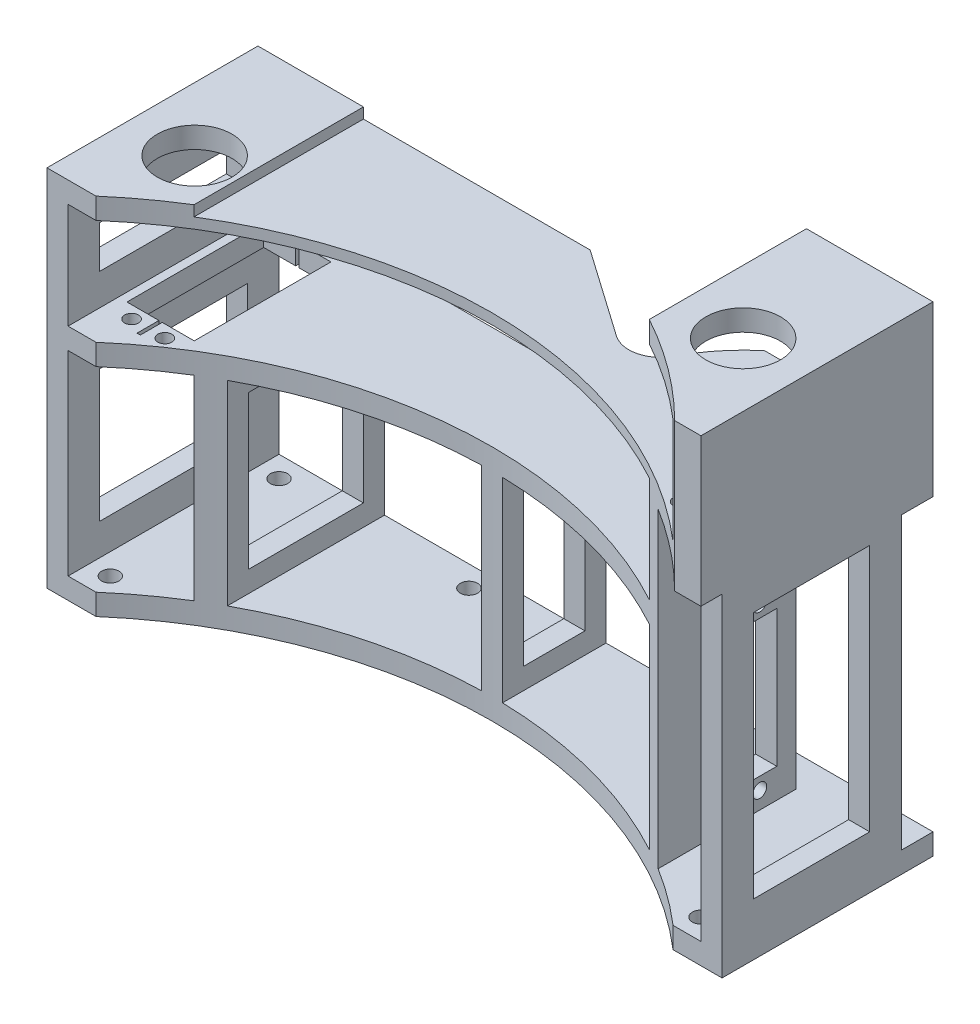
from build123d import *

# Parameters (mm, degrees)
SKETCH1_W               = 203.2
SKETCH1_H               = 106.425000002
BOSS_EXTRUDE1_DEPTH     = 31.75
SKETCH4_W               = 190.5
SKETCH4_H               = 31.75
SKETCH4_H_2             = 58.800000002
CUT_EXTRUDE2_DEPTH      = 64.5
BOSS_EXTRUDE2_START     = -31.75
SKETCH8_W               = 6.35
SKETCH8_H               = 58.800000002
SKETCH8_H_2             = 96.900000002
BOSS_EXTRUDE2_DEPTH     = 63.5
SKETCH15_W              = 25.4
SKETCH15_H              = 63.5
BOSS_EXTRUDE4_DEPTH     = 3.175
CUT_EXTRUDE3_REACH      = 73.5
SKETCH2_R               = 2.099999991
SKETCH2_W               = 25.4
SKETCH2_H               = 63.5
CUT_EXTRUDE4_REACH      = 108.425
SKETCH9_R               = 2.099999991
CUT_EXTRUDE7_START      = -1
SKETCH12_R              = 2.600000007
CUT_EXTRUDE7_DEPTH      = 7.35
SKETCH16_W              = 31.75
SKETCH16_H              = 63.5
BOSS_EXTRUDE5_DEPTH     = 3.175
CUT_EXTRUDE8_REACH      = 111.6
SKETCH17_R              = 11.2395
BOSS_EXTRUDE6_START     = -6.35
BOSS_EXTRUDE6_DEPTH     = 38.1
SKETCH20_W              = 38.1
SKETCH20_H              = 69.85
SKETCH20_R              = 11.2395
BOSS_EXTRUDE7_DEPTH     = 6.35
SKETCH10_R              = 132.699248966
CUT_EXTRUDE5_DEPTH      = 39.1
CUT_EXTRUDE5_DEPTH_BACK = 107.425000002
CUT_EXTRUDE10_DEPTH     = 3.175
SKETCH23_W              = 44.45
SKETCH23_H              = 87.375000002
CUT_EXTRUDE11_DEPTH     = 9.525
CUT_EXTRUDE12_REACH     = 40.1
SKETCH24_R              = 2.099999991
CUT_EXTRUDE13_REACH     = 8.35
SKETCH26_W              = 34.925
SKETCH26_H              = 74.675000002
CUT_EXTRUDE14_REACH     = 40.1
SKETCH27_W              = 25.085299193
SKETCH27_H              = 19.05
CUT_EXTRUDE15_REACH     = 106.775
SKETCH28_W              = 18.468739448
SKETCH28_H              = 46.100000002
CUT_EXTRUDE16_REACH     = 40.1
SKETCH29_W              = 34.610299193
SKETCH29_H              = 46.100000002
CUT_EXTRUDE17_REACH     = 8.35
SKETCH30_W              = 44.45
SKETCH30_H              = 39.750000002
CUT_EXTRUDE18_REACH     = 8.35
SKETCH31_W              = 44.45
SKETCH31_H              = 12.7
FILLET1_R               = 9.525


with BuildPart() as part:
    # Sketch1 → Boss-Extrude1 (new body, symmetric)
    with BuildSketch(Plane.XY):
        with Locations((0, 53.212500001)):
            Rectangle(SKETCH1_W, SKETCH1_H)
    extrude(amount=BOSS_EXTRUDE1_DEPTH, both=True)

    # Sketch4 → Cut-Extrude2 (cut, through all)
    with BuildSketch(Plane(origin=(0, 0, -31.75), x_dir=(-1, 0, 0), z_dir=(0, 0, -1))):
        with Locations((0, 87.375000002)):
            Rectangle(SKETCH4_W, SKETCH4_H)
        with Locations((0, 35.750000001)):
            Rectangle(SKETCH4_W, SKETCH4_H_2)
    extrude(amount=-CUT_EXTRUDE2_DEPTH, mode=Mode.SUBTRACT)

    # Sketch8 → Boss-Extrude2 (add)
    with BuildSketch(Plane.XY.offset(BOSS_EXTRUDE2_START)):
        with Locations((-66.675, 35.750000001)):
            Rectangle(SKETCH8_W, SKETCH8_H)
        with Locations((66.675, 54.800000001)):
            Rectangle(SKETCH8_W, SKETCH8_H_2)
        with Locations((0, 35.750000001)):
            Rectangle(SKETCH8_W, SKETCH8_H)
    extrude(amount=BOSS_EXTRUDE2_DEPTH)

    # Sketch15 → Boss-Extrude4 (add)
    with BuildSketch(Plane.XZ.offset(-103.250000002)):
        with Locations((82.55, 0)):
            Rectangle(SKETCH15_W, SKETCH15_H)
    extrude(amount=BOSS_EXTRUDE4_DEPTH)

    # Sketch2 → Cut-Extrude3 (cut, up to next)
    with BuildSketch(Plane(origin=(0, 71.500000002, 0), x_dir=(1, 0, 0), z_dir=(0, 1, 0)), mode=Mode.PRIVATE) as cut_extrude3_sk1:
        with Locations((-87.550000033, -20.327000113)):
            Circle(SKETCH2_R)
    cut_extrude3_tool1 = extrude(cut_extrude3_sk1.sketch, amount=-CUT_EXTRUDE3_REACH, mode=Mode.PRIVATE) & part.part
    add(cut_extrude3_tool1.solids().sort_by_distance((-87.55, 71.5, 20.327))[0], mode=Mode.SUBTRACT)
    # Sketch2 → Cut-Extrude3 (cut, up to next)
    with BuildSketch(Plane(origin=(0, 71.500000002, 0), x_dir=(1, 0, 0), z_dir=(0, 1, 0)), mode=Mode.PRIVATE) as cut_extrude3_sk2:
        with Locations((-77.549999967, -20.327000113)):
            Circle(SKETCH2_R)
    cut_extrude3_tool2 = extrude(cut_extrude3_sk2.sketch, amount=-CUT_EXTRUDE3_REACH, mode=Mode.PRIVATE) & part.part
    add(cut_extrude3_tool2.solids().sort_by_distance((-77.55, 71.5, 20.327))[0], mode=Mode.SUBTRACT)
    # Sketch2 → Cut-Extrude3 (cut, up to next)
    with BuildSketch(Plane(origin=(0, 71.500000002, 0), x_dir=(1, 0, 0), z_dir=(0, 1, 0)), mode=Mode.PRIVATE) as cut_extrude3_sk3:
        with Locations((-87.550000033, 28.272999969)):
            Circle(SKETCH2_R)
    cut_extrude3_tool3 = extrude(cut_extrude3_sk3.sketch, amount=-CUT_EXTRUDE3_REACH, mode=Mode.PRIVATE) & part.part
    add(cut_extrude3_tool3.solids().sort_by_distance((-87.55, 71.5, -28.273))[0], mode=Mode.SUBTRACT)
    # Sketch2 → Cut-Extrude3 (cut, up to next)
    with BuildSketch(Plane(origin=(0, 71.500000002, 0), x_dir=(1, 0, 0), z_dir=(0, 1, 0)), mode=Mode.PRIVATE) as cut_extrude3_sk4:
        with Locations((-77.549999967, 28.272999969)):
            Circle(SKETCH2_R)
    cut_extrude3_tool4 = extrude(cut_extrude3_sk4.sketch, amount=-CUT_EXTRUDE3_REACH, mode=Mode.PRIVATE) & part.part
    add(cut_extrude3_tool4.solids().sort_by_distance((-77.55, 71.5, -28.273))[0], mode=Mode.SUBTRACT)
    # Sketch2 → Cut-Extrude3 (cut, up to next)
    with BuildSketch(Plane(origin=(0, 71.500000002, 0), x_dir=(1, 0, 0), z_dir=(0, 1, 0)), mode=Mode.PRIVATE) as cut_extrude3_sk5:
        Polygon((-92.676999939, 24.549999922), (-83.05, 24.549999922), (-83.05, 31.153999922), (-82.05, 31.153999922), (-82.05, 24.549999922), (-72.423000061, 24.549999922), (-72.423000061, -16.604000066), (-82.05, -16.604000066), (-82.05, -23.208000066), (-83.05, -23.208000066), (-83.05, -16.604000066), (-92.676999939, -16.604000066), align=None)
    cut_extrude3_tool5 = extrude(cut_extrude3_sk5.sketch, amount=-CUT_EXTRUDE3_REACH, mode=Mode.PRIVATE) & part.part
    add(cut_extrude3_tool5.solids().sort_by_distance((-82.55, 71.5, -3.973))[0], mode=Mode.SUBTRACT)
    # Sketch2 → Cut-Extrude3 (cut, up to next)
    with BuildSketch(Plane(origin=(0, 71.500000002, 0), x_dir=(1, 0, 0), z_dir=(0, 1, 0)), mode=Mode.PRIVATE) as cut_extrude3_sk6:
        with Locations((82.55, 0)):
            Rectangle(SKETCH2_W, SKETCH2_H)
    cut_extrude3_tool6 = extrude(cut_extrude3_sk6.sketch, amount=-CUT_EXTRUDE3_REACH, mode=Mode.PRIVATE) & part.part
    add(cut_extrude3_tool6.solids().sort_by_distance((82.55, 71.5, 0))[0], mode=Mode.SUBTRACT)

    # Sketch9 → Cut-Extrude4 (cut, up to next)
    with BuildSketch(Plane(origin=(0, 106.425000002, 0), x_dir=(1, 0, 0), z_dir=(0, 1, 0)), mode=Mode.PRIVATE) as cut_extrude4_sk1:
        with Locations((77.549999967, -20.327000113)):
            Circle(SKETCH9_R)
    cut_extrude4_tool1 = extrude(cut_extrude4_sk1.sketch, amount=-CUT_EXTRUDE4_REACH, mode=Mode.PRIVATE) & part.part
    add(cut_extrude4_tool1.solids().sort_by_distance((77.55, 106.425, 20.327))[0], mode=Mode.SUBTRACT)
    # Sketch9 → Cut-Extrude4 (cut, up to next)
    with BuildSketch(Plane(origin=(0, 106.425000002, 0), x_dir=(1, 0, 0), z_dir=(0, 1, 0)), mode=Mode.PRIVATE) as cut_extrude4_sk2:
        with Locations((87.550000033, -20.327000113)):
            Circle(SKETCH9_R)
    cut_extrude4_tool2 = extrude(cut_extrude4_sk2.sketch, amount=-CUT_EXTRUDE4_REACH, mode=Mode.PRIVATE) & part.part
    add(cut_extrude4_tool2.solids().sort_by_distance((87.55, 106.425, 20.327))[0], mode=Mode.SUBTRACT)
    # Sketch9 → Cut-Extrude4 (cut, up to next)
    with BuildSketch(Plane(origin=(0, 106.425000002, 0), x_dir=(1, 0, 0), z_dir=(0, 1, 0)), mode=Mode.PRIVATE) as cut_extrude4_sk3:
        with Locations((77.549999967, 28.272999969)):
            Circle(SKETCH9_R)
    cut_extrude4_tool3 = extrude(cut_extrude4_sk3.sketch, amount=-CUT_EXTRUDE4_REACH, mode=Mode.PRIVATE) & part.part
    add(cut_extrude4_tool3.solids().sort_by_distance((77.55, 106.425, -28.273))[0], mode=Mode.SUBTRACT)
    # Sketch9 → Cut-Extrude4 (cut, up to next)
    with BuildSketch(Plane(origin=(0, 106.425000002, 0), x_dir=(1, 0, 0), z_dir=(0, 1, 0)), mode=Mode.PRIVATE) as cut_extrude4_sk4:
        with Locations((87.550000033, 28.272999969)):
            Circle(SKETCH9_R)
    cut_extrude4_tool4 = extrude(cut_extrude4_sk4.sketch, amount=-CUT_EXTRUDE4_REACH, mode=Mode.PRIVATE) & part.part
    add(cut_extrude4_tool4.solids().sort_by_distance((87.55, 106.425, -28.273))[0], mode=Mode.SUBTRACT)
    # Sketch9 → Cut-Extrude4 (cut, up to next)
    with BuildSketch(Plane(origin=(0, 106.425000002, 0), x_dir=(1, 0, 0), z_dir=(0, 1, 0)), mode=Mode.PRIVATE) as cut_extrude4_sk5:
        Polygon((72.423000061, 24.549999922), (82.05, 24.549999922), (82.05, 31.153999922), (83.05, 31.153999922), (83.05, 24.549999922), (92.676999939, 24.549999922), (92.676999939, -16.604000066), (83.05, -16.604000066), (83.05, -23.208000066), (82.05, -23.208000066), (82.05, -16.604000066), (72.423000061, -16.604000066), align=None)
    cut_extrude4_tool5 = extrude(cut_extrude4_sk5.sketch, amount=-CUT_EXTRUDE4_REACH, mode=Mode.PRIVATE) & part.part
    add(cut_extrude4_tool5.solids().sort_by_distance((82.55, 106.425, -3.973))[0], mode=Mode.SUBTRACT)

    # Sketch12 → Cut-Extrude7 (cut)
    with BuildSketch(Plane(origin=(0, 0, 0), x_dir=(1, 0, 0), z_dir=(0, 1, 0)).offset(CUT_EXTRUDE7_START)):
        with Locations((-88.9, 25.4)):
            Circle(SKETCH12_R)
        with Locations((-88.9, -25.4)):
            Circle(SKETCH12_R)
        with Locations((-31.75, 25.4)):
            Circle(SKETCH12_R)
    cut_extrude7 = extrude(amount=CUT_EXTRUDE7_DEPTH, mode=Mode.SUBTRACT)

    # Mirror1: Cut-Extrude7 across plane
    add(cut_extrude7.mirror(Plane(origin=(0, 0, 0), x_dir=(0, 0, 1), z_dir=(1, 0, 0))), mode=Mode.SUBTRACT)

    # Sketch16 → Boss-Extrude5 (add)
    with BuildSketch(Plane(origin=(0, 106.425000002, 0), x_dir=(1, 0, 0), z_dir=(0, 1, 0))):
        with Locations((-85.725, 0)):
            Rectangle(SKETCH16_W, SKETCH16_H)
    extrude(amount=BOSS_EXTRUDE5_DEPTH)

    # Sketch17 → Cut-Extrude8 (cut, up to next)
    with BuildSketch(Plane(origin=(0, 109.600000002, 0), x_dir=(1, 0, 0), z_dir=(0, 1, 0)), mode=Mode.PRIVATE) as cut_extrude8_sk1:
        with Locations((-82.55, -6.35)):
            Circle(SKETCH17_R)
    cut_extrude8_tool1 = extrude(cut_extrude8_sk1.sketch, amount=-CUT_EXTRUDE8_REACH, mode=Mode.PRIVATE) & part.part
    add(cut_extrude8_tool1.solids().sort_by_distance((-82.55, 109.6, 6.35))[0], mode=Mode.SUBTRACT)

    # Sketch18 → Boss-Extrude6 (add)
    with BuildSketch(Plane(origin=(0, 106.425000002, 0), x_dir=(1, 0, 0), z_dir=(0, 1, 0)).offset(BOSS_EXTRUDE6_START)):
        Polygon((101.6, -31.75), (101.6, 31.75), (95.25, 31.75), (95.25, -31.75), (82.55, -31.75), (82.55, -38.1), (101.6, -38.1), align=None)
    extrude(amount=BOSS_EXTRUDE6_DEPTH)

    # Sketch20 → Boss-Extrude7 (add)
    with BuildSketch(Plane(origin=(0, 138.175000002, 0), x_dir=(1, 0, 0), z_dir=(0, 1, 0))):
        with Locations((82.55, -3.175)):
            Rectangle(SKETCH20_W, SKETCH20_H)
        with Locations((82.55, -6.35)):
            Circle(SKETCH20_R, mode=Mode.SUBTRACT)
    extrude(amount=BOSS_EXTRUDE7_DEPTH)

    # Sketch10 → Cut-Extrude5 (cut, two sides)
    with BuildSketch(Plane(origin=(0, 106.425000002, 0), x_dir=(1, 0, 0), z_dir=(0, 1, 0))) as cut_extrude5_sk:
        with Locations((0, -132.08)):
            Circle(SKETCH10_R)
    extrude(amount=CUT_EXTRUDE5_DEPTH, mode=Mode.SUBTRACT)
    extrude(cut_extrude5_sk.sketch, amount=-CUT_EXTRUDE5_DEPTH_BACK, mode=Mode.SUBTRACT)

    # Sketch21 → Cut-Extrude10 (cut)
    with BuildSketch(Plane(origin=(0, 106.425000002, 0), x_dir=(1, 0, 0), z_dir=(0, 1, 0))):
        with BuildLine():
            Line((34.675884865, 6.35), (-1.599074507, 31.75))
            Line((-1.599074507, 31.75), (50.901763082, 31.75))
            ThreePointArc((50.901763082, 31.75), (40.809838057, 20.314204113), (34.675884865, 6.35))
        make_face()
    extrude(amount=-CUT_EXTRUDE10_DEPTH, mode=Mode.SUBTRACT)

    # Sketch23 → Cut-Extrude11 (cut)
    with BuildSketch(Plane(origin=(0, 0, -31.75), x_dir=(-1, 0, 0), z_dir=(0, 0, -1))):
        with Locations((-79.375, 50.037500001)):
            Rectangle(SKETCH23_W, SKETCH23_H)
    extrude(amount=-CUT_EXTRUDE11_DEPTH, mode=Mode.SUBTRACT)

    # Sketch24 → Cut-Extrude12 (cut, up to next)
    with BuildSketch(Plane.ZY.offset(-63.5), mode=Mode.PRIVATE) as cut_extrude12_sk1:
        with Locations((-11.350000033, 11.477000033)):
            Circle(SKETCH24_R)
    cut_extrude12_tool1 = extrude(cut_extrude12_sk1.sketch, amount=-CUT_EXTRUDE12_REACH, mode=Mode.PRIVATE) & part.part
    add(cut_extrude12_tool1.solids().sort_by_distance((63.5, 11.477, -11.35))[0], mode=Mode.SUBTRACT)
    # Sketch24 → Cut-Extrude12 (cut, up to next)
    with BuildSketch(Plane.ZY.offset(-63.5), mode=Mode.PRIVATE) as cut_extrude12_sk2:
        with Locations((-1.349999967, 11.477000033)):
            Circle(SKETCH24_R)
    cut_extrude12_tool2 = extrude(cut_extrude12_sk2.sketch, amount=-CUT_EXTRUDE12_REACH, mode=Mode.PRIVATE) & part.part
    add(cut_extrude12_tool2.solids().sort_by_distance((63.5, 11.477, -1.35))[0], mode=Mode.SUBTRACT)
    # Sketch24 → Cut-Extrude12 (cut, up to next)
    with BuildSketch(Plane.ZY.offset(-63.5), mode=Mode.PRIVATE) as cut_extrude12_sk3:
        with Locations((-11.350000033, 60.077000115)):
            Circle(SKETCH24_R)
    cut_extrude12_tool3 = extrude(cut_extrude12_sk3.sketch, amount=-CUT_EXTRUDE12_REACH, mode=Mode.PRIVATE) & part.part
    add(cut_extrude12_tool3.solids().sort_by_distance((63.5, 60.077, -11.35))[0], mode=Mode.SUBTRACT)
    # Sketch24 → Cut-Extrude12 (cut, up to next)
    with BuildSketch(Plane.ZY.offset(-63.5), mode=Mode.PRIVATE) as cut_extrude12_sk4:
        with Locations((-1.349999967, 60.077000115)):
            Circle(SKETCH24_R)
    cut_extrude12_tool4 = extrude(cut_extrude12_sk4.sketch, amount=-CUT_EXTRUDE12_REACH, mode=Mode.PRIVATE) & part.part
    add(cut_extrude12_tool4.solids().sort_by_distance((63.5, 60.077, -1.35))[0], mode=Mode.SUBTRACT)
    # Sketch24 → Cut-Extrude12 (cut, up to next)
    with BuildSketch(Plane.ZY.offset(-63.5), mode=Mode.PRIVATE) as cut_extrude12_sk5:
        Polygon((-16.476999939, 56.354000068), (-6.85, 56.354000068), (-6.85, 62.958000068), (-5.85, 62.958000068), (-5.85, 56.354000068), (3.776999939, 56.354000068), (3.776999939, 15.20000008), (-5.85, 15.20000008), (-5.85, 8.59600008), (-6.85, 8.59600008), (-6.85, 15.20000008), (-16.476999939, 15.20000008), align=None)
    cut_extrude12_tool5 = extrude(cut_extrude12_sk5.sketch, amount=-CUT_EXTRUDE12_REACH, mode=Mode.PRIVATE) & part.part
    add(cut_extrude12_tool5.solids().sort_by_distance((63.5, 35.777, -6.35))[0], mode=Mode.SUBTRACT)

    # Sketch26 → Cut-Extrude13 (cut, up to next)
    with BuildSketch(Plane.ZY.offset(-95.25), mode=Mode.PRIVATE) as cut_extrude13_sk1:
        with Locations((4.7625, 53.212500001)):
            Rectangle(SKETCH26_W, SKETCH26_H)
    cut_extrude13_tool1 = extrude(cut_extrude13_sk1.sketch, amount=-CUT_EXTRUDE13_REACH, mode=Mode.PRIVATE) & part.part
    add(cut_extrude13_tool1.solids().sort_by_distance((95.25, 53.2125, 4.7625))[0], mode=Mode.SUBTRACT)

    # Sketch27 → Cut-Extrude14 (cut, up to next)
    with BuildSketch(Plane.ZY.offset(-63.5), mode=Mode.PRIVATE) as cut_extrude14_sk1:
        with Locations((-3.332350404, 87.375000002)):
            Rectangle(SKETCH27_W, SKETCH27_H)
    cut_extrude14_tool1 = extrude(cut_extrude14_sk1.sketch, amount=-CUT_EXTRUDE14_REACH, mode=Mode.PRIVATE) & part.part
    add(cut_extrude14_tool1.solids().sort_by_distance((63.5, 87.375, -3.33235))[0], mode=Mode.SUBTRACT)

    # Sketch28 → Cut-Extrude15 (cut, up to next)
    with BuildSketch(Plane(origin=(3.175, 0, 0), x_dir=(0, 0, -1), z_dir=(1, 0, 0)), mode=Mode.PRIVATE) as cut_extrude15_sk1:
        with Locations((16.165630276, 35.750000001)):
            Rectangle(SKETCH28_W, SKETCH28_H)
    cut_extrude15_tool1 = extrude(cut_extrude15_sk1.sketch, amount=-CUT_EXTRUDE15_REACH, mode=Mode.PRIVATE) & part.part
    add(cut_extrude15_tool1.solids().sort_by_distance((3.175, 35.75, -16.16563))[0], mode=Mode.SUBTRACT)

    # Sketch29 → Cut-Extrude16 (cut, up to next)
    with BuildSketch(Plane(origin=(-63.5, 0, 0), x_dir=(0, 0, -1), z_dir=(1, 0, 0)), mode=Mode.PRIVATE) as cut_extrude16_sk1:
        with Locations((8.094850404, 35.750000001)):
            Rectangle(SKETCH29_W, SKETCH29_H)
    cut_extrude16_tool1 = extrude(cut_extrude16_sk1.sketch, amount=-CUT_EXTRUDE16_REACH, mode=Mode.PRIVATE) & part.part
    add(cut_extrude16_tool1.solids().sort_by_distance((-63.5, 35.75, -8.09485))[0], mode=Mode.SUBTRACT)

    # Sketch30 → Cut-Extrude17 (cut, up to next)
    with BuildSketch(Plane(origin=(-95.25, 0, 0), x_dir=(0, 0, -1), z_dir=(1, 0, 0)), mode=Mode.PRIVATE) as cut_extrude17_sk1:
        with Locations((0, 35.750000001)):
            Rectangle(SKETCH30_W, SKETCH30_H)
    cut_extrude17_tool1 = extrude(cut_extrude17_sk1.sketch, amount=-CUT_EXTRUDE17_REACH, mode=Mode.PRIVATE) & part.part
    add(cut_extrude17_tool1.solids().sort_by_distance((-95.25, 35.75, 0))[0], mode=Mode.SUBTRACT)

    # Sketch31 → Cut-Extrude18 (cut, up to next)
    with BuildSketch(Plane(origin=(-95.25, 0, 0), x_dir=(0, 0, -1), z_dir=(1, 0, 0)), mode=Mode.PRIVATE) as cut_extrude18_sk1:
        with Locations((0, 87.375000002)):
            Rectangle(SKETCH31_W, SKETCH31_H)
    cut_extrude18_tool1 = extrude(cut_extrude18_sk1.sketch, amount=-CUT_EXTRUDE18_REACH, mode=Mode.PRIVATE) & part.part
    add(cut_extrude18_tool1.solids().sort_by_distance((-95.25, 87.375, 0))[0], mode=Mode.SUBTRACT)

    # Fillet1
    fillet1_edges = [part.edges().sort_by_distance(p)[0] for p in [
        (34.675884865, 104.837500002, -6.35),
    ]]
    fillet(fillet1_edges, radius=FILLET1_R)


solid = part.part
